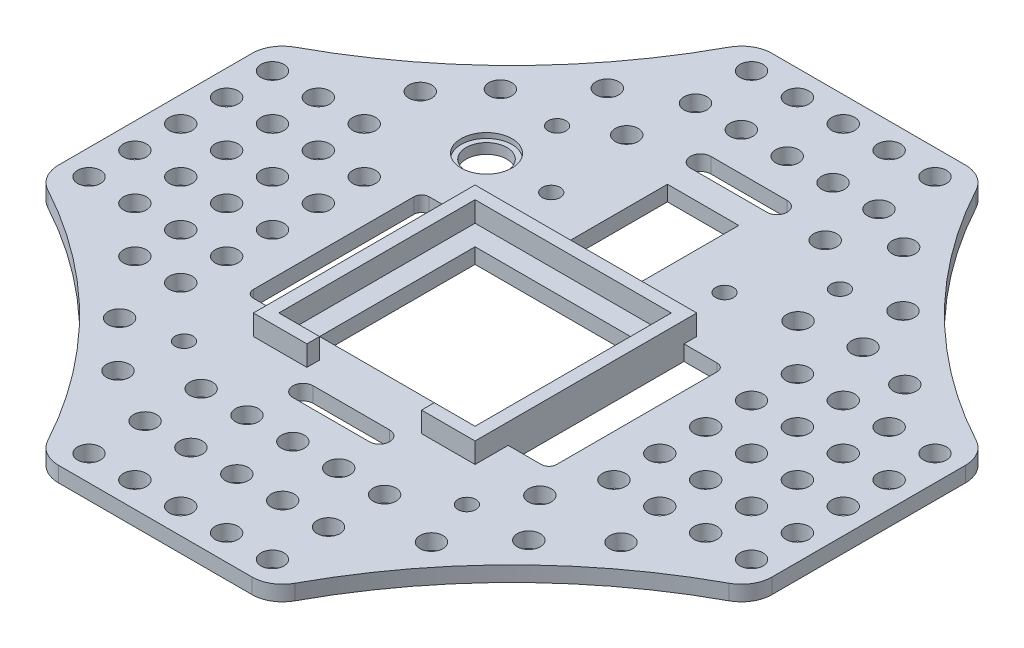
from build123d import *

# Parameters (mm, degrees)
SKETCH1_W                 = 64
SKETCH1_H                 = 82
SKETCH1_R                 = 1.75
BOSS_EXTRUDE1_DEPTH       = 3
GPS_HOUSING_DEPTH         = 4
SKETCH3_R                 = 1.75
SPECTRUM_COVER_HOLE_DEPTH = 4
TAPE_SLOT_DEPTH           = 4
SKETCH6_W                 = 64
SKETCH6_H                 = 82
EXTENSION_DEPTH           = 3
SKETCH7_R                 = 4
ARM_BUTTON_HOLE_DEPTH     = 4
SKETCH8_R                 = 5
CUT_EXTRUDE4_DEPTH        = 1
WIRE_SLOT_DEPTH           = 4
SKETCH10_R                = 2.25
MARKERS_HOLE_DEPTH        = 4
FILLET1_R                 = 6
SKETCH11_W                = 30.5
SKETCH11_H                = 30.5
SKETCH11_W_2              = 14
SKETCH11_H_2              = 19
WEIGHT_REDUCER_DEPTH      = 4


with BuildPart() as part:
    # Sketch1 → Boss-Extrude1 (new body)
    with BuildSketch(Plane(origin=(0, 0, 0), x_dir=(1, 0, 0), z_dir=(0, 1, 0))):
        Rectangle(SKETCH1_W, SKETCH1_H)
        with Locations((27.75, -36.6)):
            Circle(SKETCH1_R, mode=Mode.SUBTRACT)
        with Locations((-27.75, -36.6)):
            Circle(SKETCH1_R, mode=Mode.SUBTRACT)
        with Locations((27.75, 36.6)):
            Circle(SKETCH1_R, mode=Mode.SUBTRACT)
        with Locations((-27.75, 36.6)):
            Circle(SKETCH1_R, mode=Mode.SUBTRACT)
    extrude(amount=BOSS_EXTRUDE1_DEPTH)

    # Sketch2 → GPS-Housing (add)
    with BuildSketch(Plane(origin=(0, 3, 0), x_dir=(1, 0, 0), z_dir=(0, 1, 0))):
        Polygon((-11.25, -26.5), (-11.25, -29), (-21.75, -29), (-21.75, 14.5), (21.75, 14.5), (21.75, -29), (11.25, -29), (11.25, -26.5), (19.25, -26.5), (19.25, 12), (-19.25, 12), (-19.25, -26.5), align=None)
    extrude(amount=GPS_HOUSING_DEPTH)

    # Sketch3 → Spectrum-Cover-Hole (cut, through all)
    with BuildSketch(Plane(origin=(0, 3, 0), x_dir=(1, 0, 0), z_dir=(0, 1, 0))):
        with Locations((-17, 24.7)):
            Circle(SKETCH3_R)
        with Locations((17, 24.7)):
            Circle(SKETCH3_R)
    extrude(amount=-SPECTRUM_COVER_HOLE_DEPTH, mode=Mode.SUBTRACT)

    # Sketch4 → Tape-Slot (cut, through all)
    with BuildSketch(Plane(origin=(0, 3, 0), x_dir=(1, 0, 0), z_dir=(0, 1, 0))):
        with BuildLine():
            Line((-21.75, 12), (-28.25, 12))
            ThreePointArc((-28.25, 12), (-29.310660172, 11.560660172), (-29.75, 10.5))
            Line((-29.75, 10.5), (-29.75, -21))
            ThreePointArc((-29.75, -21), (-29.310660172, -22.060660172), (-28.25, -22.5))
            Line((-28.25, -22.5), (-21.75, -22.5))
            Line((-21.75, -22.5), (-21.75, 12))
        make_face()
        with BuildLine():
            Line((29.75, 10.5), (29.75, -21))
            ThreePointArc((29.75, -21), (29.310660172, -22.060660172), (28.25, -22.5))
            Line((28.25, -22.5), (21.75, -22.5))
            Line((21.75, -22.5), (21.75, 12))
            Line((21.75, 12), (28.25, 12))
            ThreePointArc((28.25, 12), (29.310660172, 11.560660172), (29.75, 10.5))
        make_face()
    extrude(amount=-TAPE_SLOT_DEPTH, mode=Mode.SUBTRACT)

    # Sketch6 → Extension (add)
    with BuildSketch(Plane(origin=(0, 3, 0), x_dir=(1, 0, 0), z_dir=(0, 1, 0))):
        with BuildLine():
            Line((70, 22.615898533), (70, -22.615898533))
            ThreePointArc((70, -22.615898533), (42.426406871, -42.426406871), (22.615898533, -70))
            Line((22.615898533, -70), (-22.615898533, -70))
            ThreePointArc((-22.615898533, -70), (-42.426406871, -42.426406871), (-70, -22.615898533))
            Line((-70, -22.615898533), (-70, 22.615898533))
            ThreePointArc((-70, 22.615898533), (-42.426406871, 42.426406871), (-22.615898533, 70))
            Line((-22.615898533, 70), (22.615898533, 70))
            ThreePointArc((22.615898533, 70), (42.426406871, 42.426406871), (70, 22.615898533))
        make_face()
        Rectangle(SKETCH6_W, SKETCH6_H, mode=Mode.SUBTRACT)
    extrude(amount=-EXTENSION_DEPTH)

    # Sketch7 → Arm-Button-Hole (cut, through all)
    with BuildSketch(Plane(origin=(0, 3, 0), x_dir=(1, 0, 0), z_dir=(0, 1, 0))):
        with Locations((-30, 25)):
            Circle(SKETCH7_R)
    extrude(amount=-ARM_BUTTON_HOLE_DEPTH, mode=Mode.SUBTRACT)

    # Sketch8 → Cut-Extrude4 (cut)
    with BuildSketch(Plane(origin=(0, 3, 0), x_dir=(1, 0, 0), z_dir=(0, 1, 0))):
        with Locations((-30, 25)):
            Circle(SKETCH8_R)
    extrude(amount=-CUT_EXTRUDE4_DEPTH, mode=Mode.SUBTRACT)

    # Sketch9 → Wire-Slot (cut, through all)
    with BuildSketch(Plane(origin=(0, 3, 0), x_dir=(1, 0, 0), z_dir=(0, 1, 0))):
        with BuildLine():
            Line((-7.5, 46.5), (7.5, 46.5))
            ThreePointArc((7.5, 46.5), (9.5, 44.5), (7.5, 42.5))
            Line((7.5, 42.5), (-7.5, 42.5))
            ThreePointArc((-7.5, 42.5), (-9.5, 44.5), (-7.5, 46.5))
        make_face()
        with BuildLine():
            Line((-7.5, -31.5), (7.5, -31.5))
            ThreePointArc((7.5, -31.5), (9.5, -33.5), (7.5, -35.5))
            Line((7.5, -35.5), (-7.5, -35.5))
            ThreePointArc((-7.5, -35.5), (-9.5, -33.5), (-7.5, -31.5))
        make_face()
    extrude(amount=-WIRE_SLOT_DEPTH, mode=Mode.SUBTRACT)

    # Sketch10 → Markers-Hole (cut, through all)
    with BuildSketch(Plane(origin=(0, 3, 0), x_dir=(1, 0, 0), z_dir=(0, 1, 0))):
        with Locations((-65, 18)):
            Circle(SKETCH10_R)
        with Locations((-56, 18)):
            Circle(SKETCH10_R)
        with Locations((-47, 18)):
            Circle(SKETCH10_R)
        with Locations((-47, -27)):
            Circle(SKETCH10_R)
        with Locations((-56, 9)):
            Circle(SKETCH10_R)
        with Locations((-47, 9)):
            Circle(SKETCH10_R)
        with Locations((-38, 9)):
            Circle(SKETCH10_R)
        with Locations((-56, 0)):
            Circle(SKETCH10_R)
        with Locations((-47, 0)):
            Circle(SKETCH10_R)
        with Locations((-38, 0)):
            Circle(SKETCH10_R)
        with Locations((-56, -9)):
            Circle(SKETCH10_R)
        with Locations((-47, -9)):
            Circle(SKETCH10_R)
        with Locations((-38, -9)):
            Circle(SKETCH10_R)
        with Locations((-56, -18)):
            Circle(SKETCH10_R)
        with Locations((-47, -18)):
            Circle(SKETCH10_R)
        with Locations((-38, -18)):
            Circle(SKETCH10_R)
        with Locations((-65, 9)):
            Circle(SKETCH10_R)
        with Locations((-65, 0)):
            Circle(SKETCH10_R)
        with Locations((-65, -9)):
            Circle(SKETCH10_R)
        with Locations((-65, -18)):
            Circle(SKETCH10_R)
        with Locations((65, -18)):
            Circle(SKETCH10_R)
        with Locations((65, -9)):
            Circle(SKETCH10_R)
        with Locations((65, 0)):
            Circle(SKETCH10_R)
        with Locations((65, 9)):
            Circle(SKETCH10_R)
        with Locations((38, -18)):
            Circle(SKETCH10_R)
        with Locations((47, -18)):
            Circle(SKETCH10_R)
        with Locations((56, -18)):
            Circle(SKETCH10_R)
        with Locations((38, -9)):
            Circle(SKETCH10_R)
        with Locations((47, -9)):
            Circle(SKETCH10_R)
        with Locations((56, -9)):
            Circle(SKETCH10_R)
        with Locations((38, 0)):
            Circle(SKETCH10_R)
        with Locations((47, 0)):
            Circle(SKETCH10_R)
        with Locations((56, 0)):
            Circle(SKETCH10_R)
        with Locations((38, 9)):
            Circle(SKETCH10_R)
        with Locations((47, 9)):
            Circle(SKETCH10_R)
        with Locations((56, 9)):
            Circle(SKETCH10_R)
        with Locations((38, 18)):
            Circle(SKETCH10_R)
        with Locations((47, 18)):
            Circle(SKETCH10_R)
        with Locations((56, 18)):
            Circle(SKETCH10_R)
        with Locations((65, 18)):
            Circle(SKETCH10_R)
        with Locations((-18, 65)):
            Circle(SKETCH10_R)
        with Locations((-18, 54)):
            Circle(SKETCH10_R)
        with Locations((0, -65)):
            Circle(SKETCH10_R)
        with Locations((-9, 65)):
            Circle(SKETCH10_R)
        with Locations((-9, 54)):
            Circle(SKETCH10_R)
        with Locations((0, 65)):
            Circle(SKETCH10_R)
        with Locations((0, -54)):
            Circle(SKETCH10_R)
        with Locations((0, 54)):
            Circle(SKETCH10_R)
        with Locations((9, 65)):
            Circle(SKETCH10_R)
        with Locations((9, 54)):
            Circle(SKETCH10_R)
        with Locations((0, -43)):
            Circle(SKETCH10_R)
        with Locations((18, 54)):
            Circle(SKETCH10_R)
        with Locations((18, 65)):
            Circle(SKETCH10_R)
        with Locations((-38, -27)):
            Circle(SKETCH10_R)
        with Locations((-38, -39)):
            Circle(SKETCH10_R)
        with Locations((18, -43)):
            Circle(SKETCH10_R)
        with Locations((18, -54)):
            Circle(SKETCH10_R)
        with Locations((-18, -43)):
            Circle(SKETCH10_R)
        with Locations((-9, -43)):
            Circle(SKETCH10_R)
        with Locations((9, -43)):
            Circle(SKETCH10_R)
        with Locations((-18, -54)):
            Circle(SKETCH10_R)
        with Locations((-9, -54)):
            Circle(SKETCH10_R)
        with Locations((9, -54)):
            Circle(SKETCH10_R)
        with Locations((-18, -65)):
            Circle(SKETCH10_R)
        with Locations((-9, -65)):
            Circle(SKETCH10_R)
        with Locations((9, -65)):
            Circle(SKETCH10_R)
        with Locations((18, -65)):
            Circle(SKETCH10_R)
        with Locations((-47, 29)):
            Circle(SKETCH10_R)
        with Locations((-29.199766043, -48.112063321)):
            Circle(SKETCH10_R)
        with Locations((29.055439622, 27.077208332)):
            Circle(SKETCH10_R)
        with Locations((39.889056776, 29)):
            Circle(SKETCH10_R)
        with Locations((37.639056776, 39.078941605)):
            Circle(SKETCH10_R)
        with Locations((50.330491129, 26.75)):
            Circle(SKETCH10_R)
        with Locations((-29.199766043, 47.904784423)):
            Circle(SKETCH10_R)
        with Locations((26.88164808, 49.967059315)):
            Circle(SKETCH10_R)
        with Locations((33.351003158, -27.890341564)):
            Circle(SKETCH10_R)
        with Locations((49.282846311, -27.890341564)):
            Circle(SKETCH10_R)
        with Locations((30.654147016, -46.463725683)):
            Circle(SKETCH10_R)
        with Locations((39.889056776, -36.594729796)):
            Circle(SKETCH10_R)
        with Locations((-19.365980237, 41.877769231)):
            Circle(SKETCH10_R)
        with Locations((18, 43.458879424)):
            Circle(SKETCH10_R)
        with Locations((-39.541070198, 37.261975635)):
            Circle(SKETCH10_R)
    extrude(amount=-MARKERS_HOLE_DEPTH, mode=Mode.SUBTRACT)

    # Fillet1
    fillet1_edges = [part.edges().sort_by_distance(p)[0] for p in [
        (70, 1.5, 22.615898533),
        (22.615898533, 1.5, 70),
        (-22.615898533, 1.5, 70),
        (-70, 1.5, 22.615898533),
        (-70, 1.5, -22.615898533),
        (-22.615898533, 1.5, -70),
        (22.615898533, 1.5, -70),
        (70, 1.5, -22.615898533),
    ]]
    fillet(fillet1_edges, radius=FILLET1_R)

    # Sketch11 → Weight-Reducer (cut, through all)
    with BuildSketch(Plane(origin=(0, 3, 0), x_dir=(1, 0, 0), z_dir=(0, 1, 0))):
        with Locations((0, -7.25)):
            Rectangle(SKETCH11_W, SKETCH11_H)
        with Locations((0, 28)):
            Rectangle(SKETCH11_W_2, SKETCH11_H_2)
    extrude(amount=-WEIGHT_REDUCER_DEPTH, mode=Mode.SUBTRACT)


solid = part.part
